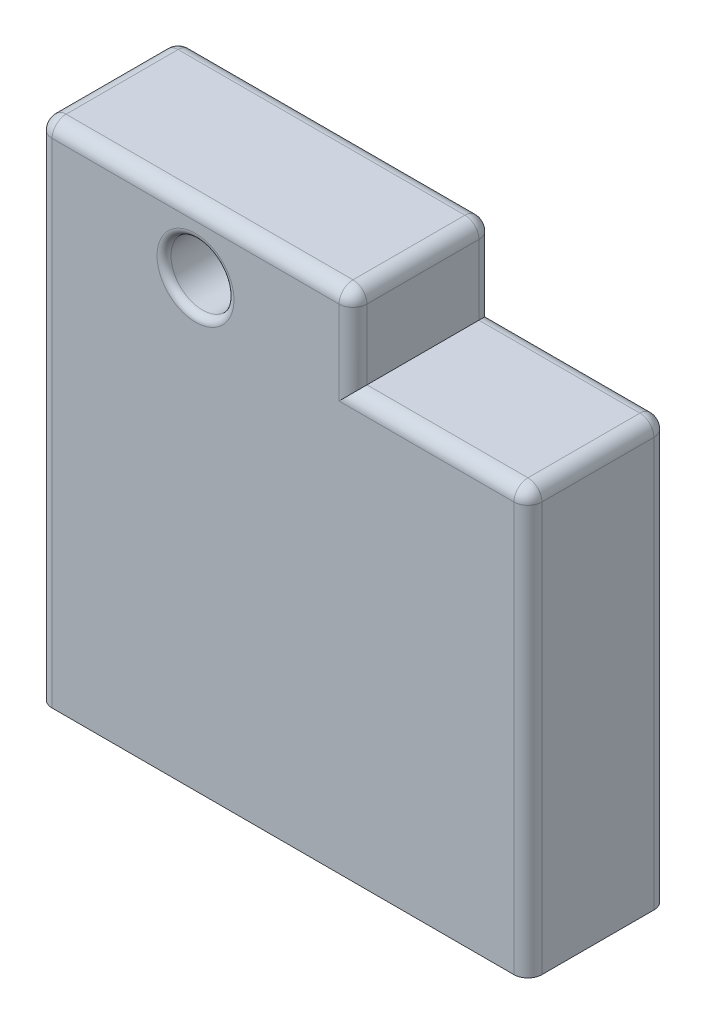
from build123d import *

# Parameters (mm, degrees)
BOSS_EXTRUDE1_DEPTH = 25.4
SKETCH9_R           = 5.715
CUT_EXTRUDE1_DEPTH  = 26.4
FILLET9_R           = 2.54
FILLET10_R          = 1.27


with BuildPart() as part:
    # Sketch2 → Boss-Extrude1 (new body)
    with BuildSketch(Plane.XY):
        Polygon((0, 0), (0, 92.075), (18.075, 92.075), (38.575, 92.075), (57.15, 92.075), (57.15, 76.835), (88.9, 76.835), (88.9, 0), align=None)
    extrude(amount=BOSS_EXTRUDE1_DEPTH)

    # Sketch9 → Cut-Extrude1 (cut, through all)
    with BuildSketch(Plane.XY.offset(25.4)):
        with Locations((28.566361876, 80.645)):
            Circle(SKETCH9_R)
    extrude(amount=-CUT_EXTRUDE1_DEPTH, mode=Mode.SUBTRACT)

    # Fillet9
    fillet9_edges = [part.edges().sort_by_distance(p)[0] for p in [
        (57.15, 84.455, 0),
        (73.025, 76.835, 0),
        (88.9, 38.4175, 0),
        (73.025, 76.835, 25.4),
        (0, 92.075, 12.7),
        (57.15, 92.075, 12.7),
        (88.9, 76.835, 12.7),
        (57.15, 84.455, 25.4),
        (28.575, 92.075, 25.4),
        (0, 46.0375, 25.4),
        (0, 46.0375, 0),
        (88.9, 38.4175, 25.4),
        (28.575, 92.075, 0),
    ]]
    fillet(fillet9_edges, radius=FILLET9_R)

    # Fillet10
    fillet10_edges = [part.edges().sort_by_distance(p)[0] for p in [
        (22.851361876, 80.645, 0),
        (22.851361876, 80.645, 25.4),
    ]]
    fillet(fillet10_edges, radius=FILLET10_R)


solid = part.part
